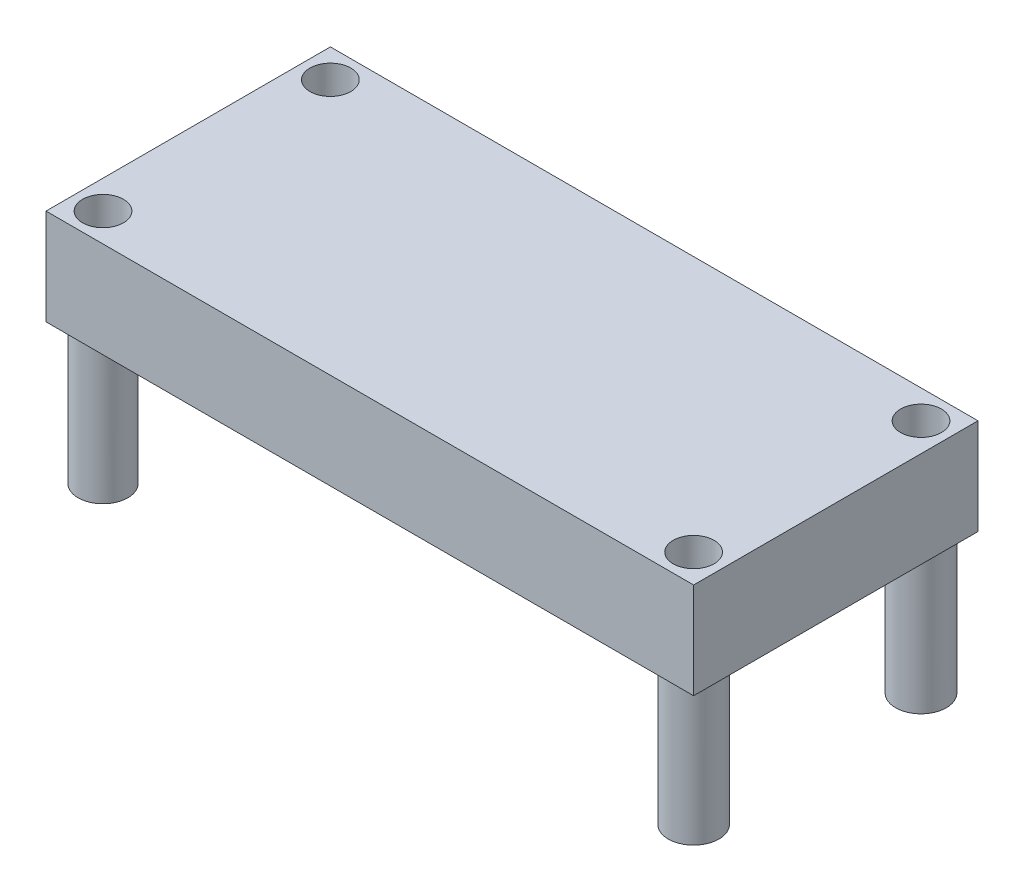
from build123d import *

# Parameters (mm, degrees)
SKETCH1_W           = 51.943
SKETCH1_H           = 22.8092
BOSS_EXTRUDE1_DEPTH = 7.6962
SKETCH2_R           = 1.9939
SKETCH2_R_2         = 2.032
BOSS_EXTRUDE2_DEPTH = 11.2268
SKETCH3_R           = 1.6383
CUT_EXTRUDE1_DEPTH  = 19.923


with BuildPart() as part:
    # Sketch1 → Boss-Extrude1 (new body)
    with BuildSketch(Plane(origin=(0, 0, 0), x_dir=(1, 0, 0), z_dir=(0, 1, 0))):
        with Locations((9.107555138, 0.071457393)):
            Rectangle(SKETCH1_W, SKETCH1_H)
    extrude(amount=BOSS_EXTRUDE1_DEPTH)

    # Sketch2 → Boss-Extrude2 (add)
    with BuildSketch(Plane.XZ):
        with Locations((-14.577944862, 9.047142607)):
            Circle(SKETCH2_R)
        with Locations((32.793055138, 9.047142607)):
            Circle(SKETCH2_R_2)
        with Locations((32.793055138, -9.190057393)):
            Circle(SKETCH2_R_2)
        with Locations((-14.577944862, -9.190057393)):
            Circle(SKETCH2_R_2)
    extrude(amount=BOSS_EXTRUDE2_DEPTH)

    # Sketch3 → Cut-Extrude1 (cut, through all)
    with BuildSketch(Plane.XZ.offset(11.2268)):
        with Locations((-14.577944862, 9.047142607)):
            Circle(SKETCH3_R)
        with Locations((-14.577944862, -9.190057393)):
            Circle(SKETCH3_R)
        with Locations((32.793055138, -9.190057393)):
            Circle(SKETCH3_R)
        with Locations((32.793055138, 9.047142607)):
            Circle(SKETCH3_R)
    extrude(amount=-CUT_EXTRUDE1_DEPTH, mode=Mode.SUBTRACT)


solid = part.part
